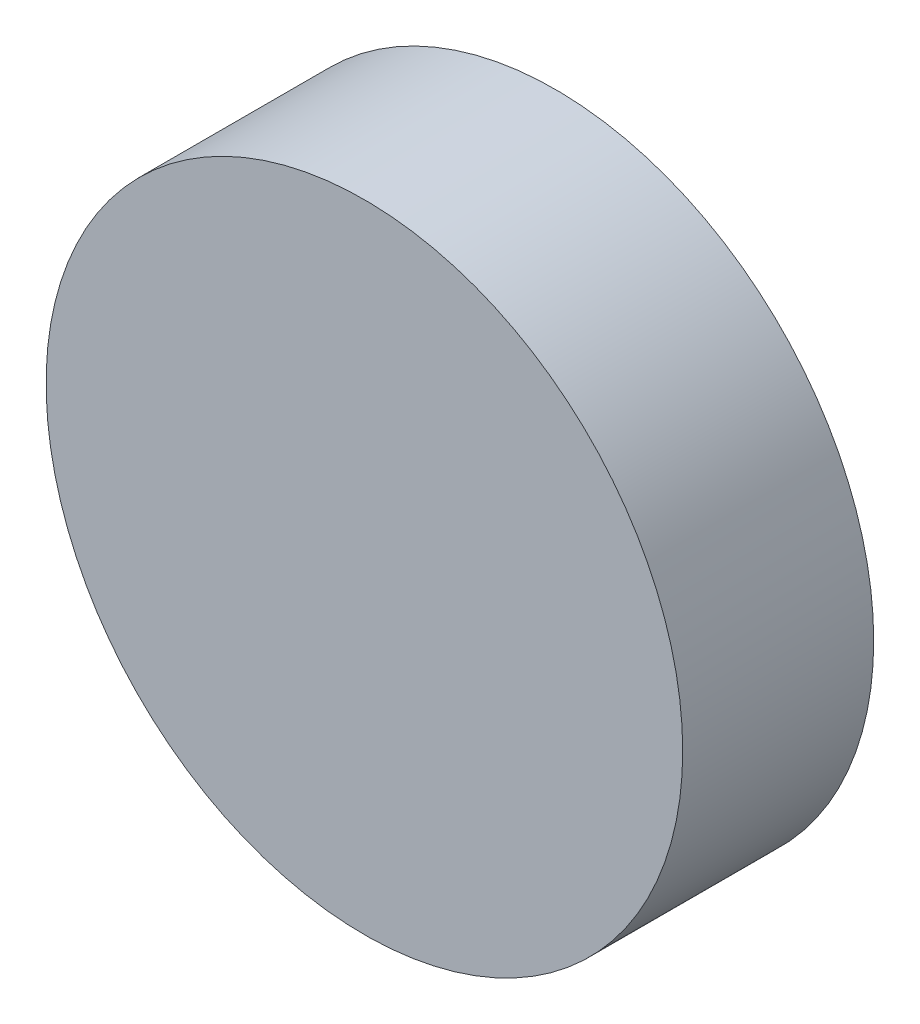
from build123d import *

# Parameters (mm, degrees)
SKETCH1_R           = 2.5
BOSS_EXTRUDE1_DEPTH = 1.5


with BuildPart() as part:
    # Sketch1 → Boss-Extrude1 (new body)
    with BuildSketch(Plane.XY):
        Circle(SKETCH1_R)
    extrude(amount=BOSS_EXTRUDE1_DEPTH)


solid = part.part
